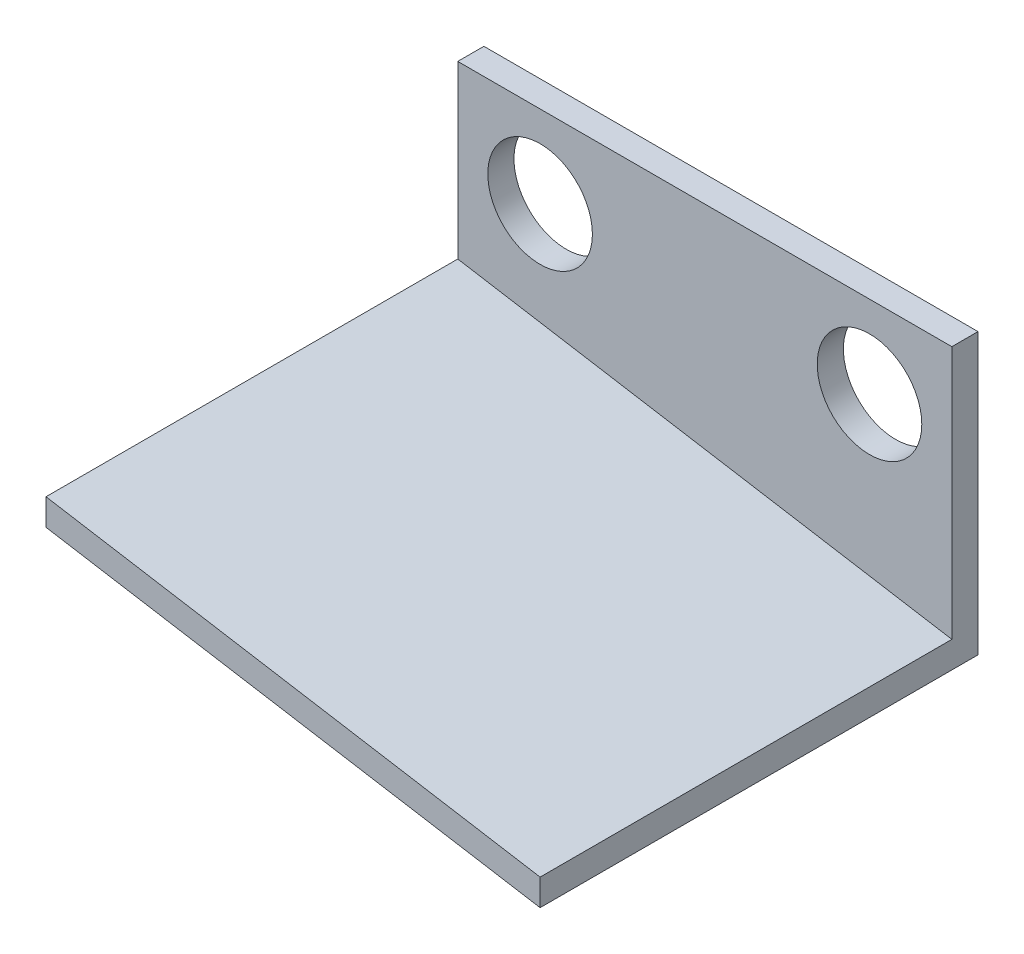
from build123d import *

# Parameters (mm, degrees)
CROQUIS3_R              = 3.175
SALIENTE_EXTRUIR2_DEPTH = 1.5875
SALIENTE_EXTRUIR3_DEPTH = 25


with BuildPart() as part:
    # Croquis3 → Saliente-Extruir2 (new body)
    with BuildSketch(Plane.XY):
        Polygon((0, -17), (0, 0), (-30, 0), (-30, -12), align=None)
        with Locations((-25, -5)):
            Circle(CROQUIS3_R, mode=Mode.SUBTRACT)
        with Locations((-5, -5)):
            Circle(CROQUIS3_R, mode=Mode.SUBTRACT)
    extrude(amount=SALIENTE_EXTRUIR2_DEPTH)

    # Croquis4 → Saliente-Extruir3 (add)
    with BuildSketch(Plane.XY.offset(1.5875)):
        Polygon((-30, -12), (0, -17), (0, -15.390602414), (-30, -10.390602414), align=None)
    extrude(amount=SALIENTE_EXTRUIR3_DEPTH)


solid = part.part
